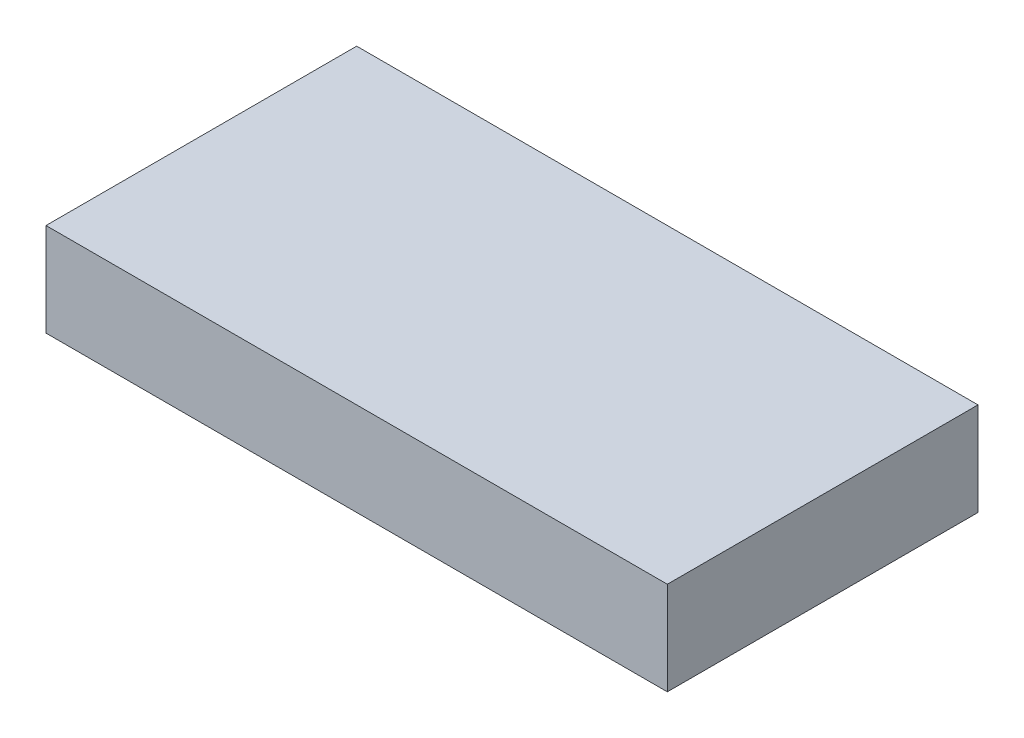
from build123d import *

# Parameters (mm, degrees)
SKETCH1_W           = 10.16
SKETCH1_H           = 5.08
BOSS_EXTRUDE1_DEPTH = 1.524


with BuildPart() as part:
    # Sketch1 → Boss-Extrude1 (new body)
    with BuildSketch(Plane(origin=(0, 0, 0), x_dir=(1, 0, 0), z_dir=(0, 1, 0))):
        Rectangle(SKETCH1_W, SKETCH1_H)
    extrude(amount=BOSS_EXTRUDE1_DEPTH)


solid = part.part
